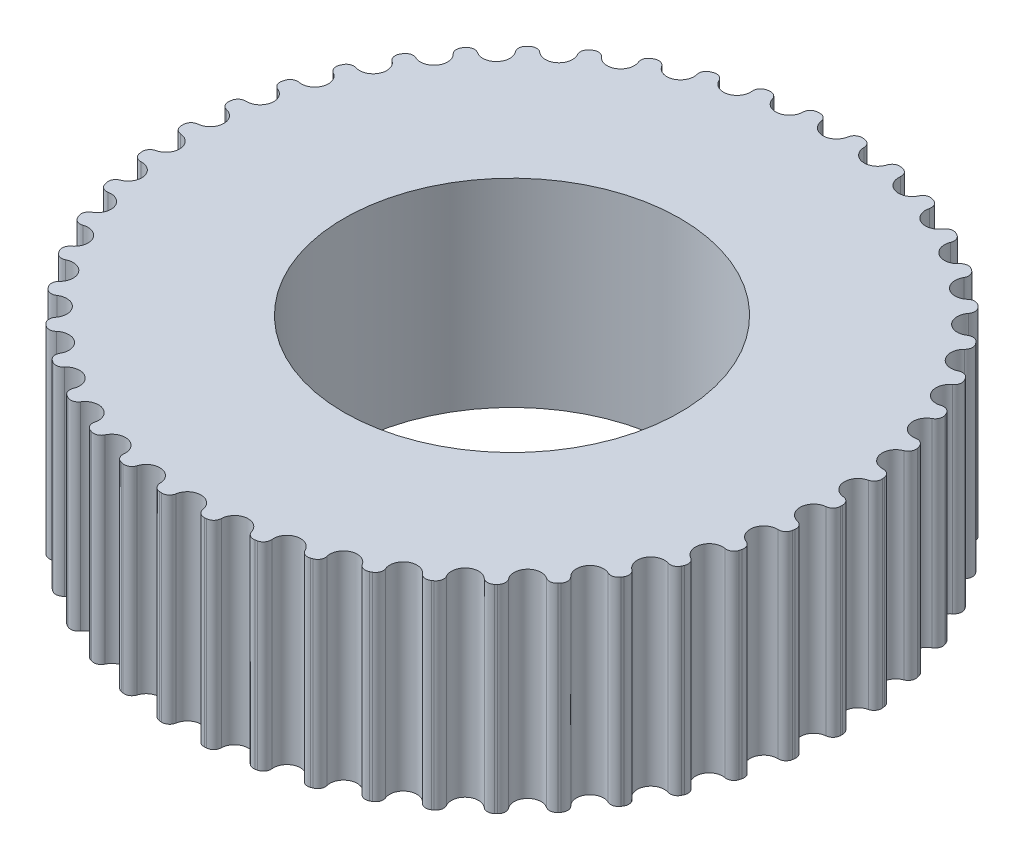
from build123d import *

# Parameters (mm, degrees)
BOSS_EXTRUDE1_DEPTH     = 6.499999954
CIRPATTERN1_COUNT       = 46
SKETCH3_R               = 10.999999971
CUT_EXTRUDE1_DEPTH      = 7.499999954
CUT_EXTRUDE1_DEPTH_BACK = 7.499999954


with BuildPart() as part:
    # Sketch1 → Boss-Extrude1 (new body, symmetric)
    with BuildSketch(Plane(origin=(0, 0, 0), x_dir=(1, 0, 0), z_dir=(0, 1, 0))):
        with BuildLine():
            ThreePointArc((0, 20.3620314), (0.578665758, 20.57583177), (0.879311396, 21.114512434))
            ThreePointArc((0.879311396, 21.114512434), (1.060765828, 21.427534351), (1.405877127, 21.536192634))
            ThreePointArc((1.405877127, 21.536192634), (1.472809915, 21.531718803), (1.539728474, 21.527036951))
            ThreePointArc((1.539728474, 21.527036951), (1.866829754, 21.372398068), (2.003970963, 21.037583612))
            ThreePointArc((2.003970963, 21.037583612), (2.228466031, 20.46298234), (2.772629585, 20.172378341))
            ThreePointArc((2.772629585, 20.172378341), (-1.389554164, -20.314562805), (0, 20.3620314))
        make_face()
    boss_extrude1 = extrude(amount=BOSS_EXTRUDE1_DEPTH, both=True)

    # CirPattern1: Boss-Extrude1 ×46 about axis
    cirpattern1_axis = Axis((0, 0, 0), (0, 1, 0))
    for i in range(1, CIRPATTERN1_COUNT):
        add(boss_extrude1.rotate(cirpattern1_axis, i * 360 / CIRPATTERN1_COUNT))

    # Sketch3 → Cut-Extrude1 (cut, two sides)
    with BuildSketch(Plane(origin=(0, 0, 0), x_dir=(-1, 0, 0), z_dir=(0, -1, 0))) as cut_extrude1_sk:
        Circle(SKETCH3_R)
    extrude(amount=CUT_EXTRUDE1_DEPTH, mode=Mode.SUBTRACT)
    extrude(cut_extrude1_sk.sketch, amount=-CUT_EXTRUDE1_DEPTH_BACK, mode=Mode.SUBTRACT)


solid = part.part
